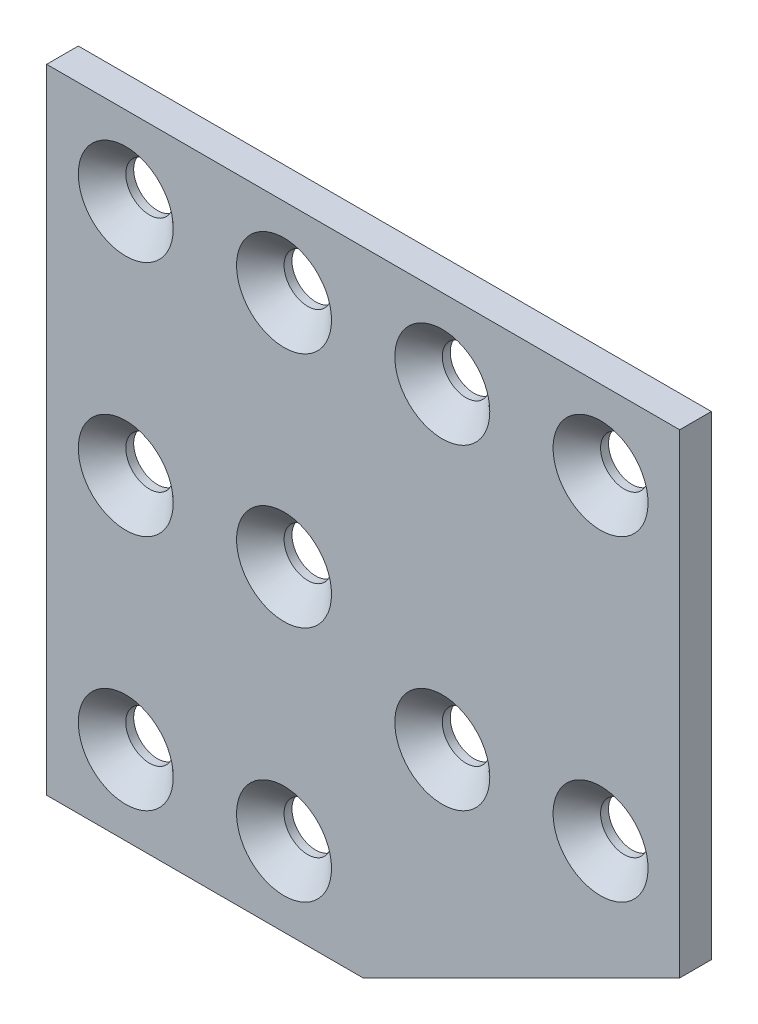
from build123d import *

# Parameters (mm, degrees)
SKETCH1_W           = 40
SKETCH1_H           = 80
SKETCH1_H_2         = 60
BOSS_EXTRUDE1_DEPTH = 2
SKETCH2_R           = 3
CUT_EXTRUDE1_DEPTH  = 5
CHAMFER1_SIZE       = 3


with BuildPart() as part:
    # Sketch1 → Boss-Extrude1 (new body, symmetric)
    with BuildSketch(Plane.XY):
        Rectangle(SKETCH1_W, SKETCH1_H)
        Polygon((20, -20), (20, -40), (60, -20), align=None)
        with Locations((40, 10)):
            Rectangle(SKETCH1_W, SKETCH1_H_2)
    extrude(amount=BOSS_EXTRUDE1_DEPTH, both=True)

    # Sketch2 → Cut-Extrude1 (cut, through all)
    with BuildSketch(Plane.XY.offset(2)):
        with Locations((50, 30)):
            Circle(SKETCH2_R)
        with Locations((30, 30)):
            Circle(SKETCH2_R)
        with Locations((50, -10)):
            Circle(SKETCH2_R)
        with Locations((30, -10)):
            Circle(SKETCH2_R)
        with Locations((-10, 30)):
            Circle(SKETCH2_R)
        with Locations((10, 30)):
            Circle(SKETCH2_R)
        with Locations((-10, 0)):
            Circle(SKETCH2_R)
        with Locations((10, 0)):
            Circle(SKETCH2_R)
        with Locations((-10, -30)):
            Circle(SKETCH2_R)
        with Locations((10, -30)):
            Circle(SKETCH2_R)
    extrude(amount=-CUT_EXTRUDE1_DEPTH, mode=Mode.SUBTRACT)

    # Chamfer1
    chamfer1_edges = [part.edges().sort_by_distance(p)[0] for p in [
        (7, 30, 2),
        (-13, 0, 2),
        (7, 0, 2),
        (-13, -30, 2),
        (27, 30, 2),
        (47, -10, 2),
        (27, -10, 2),
        (-13, 30, 2),
        (7, -30, 2),
        (47, 30, 2),
    ]]
    chamfer(chamfer1_edges, length=CHAMFER1_SIZE)


solid = part.part
